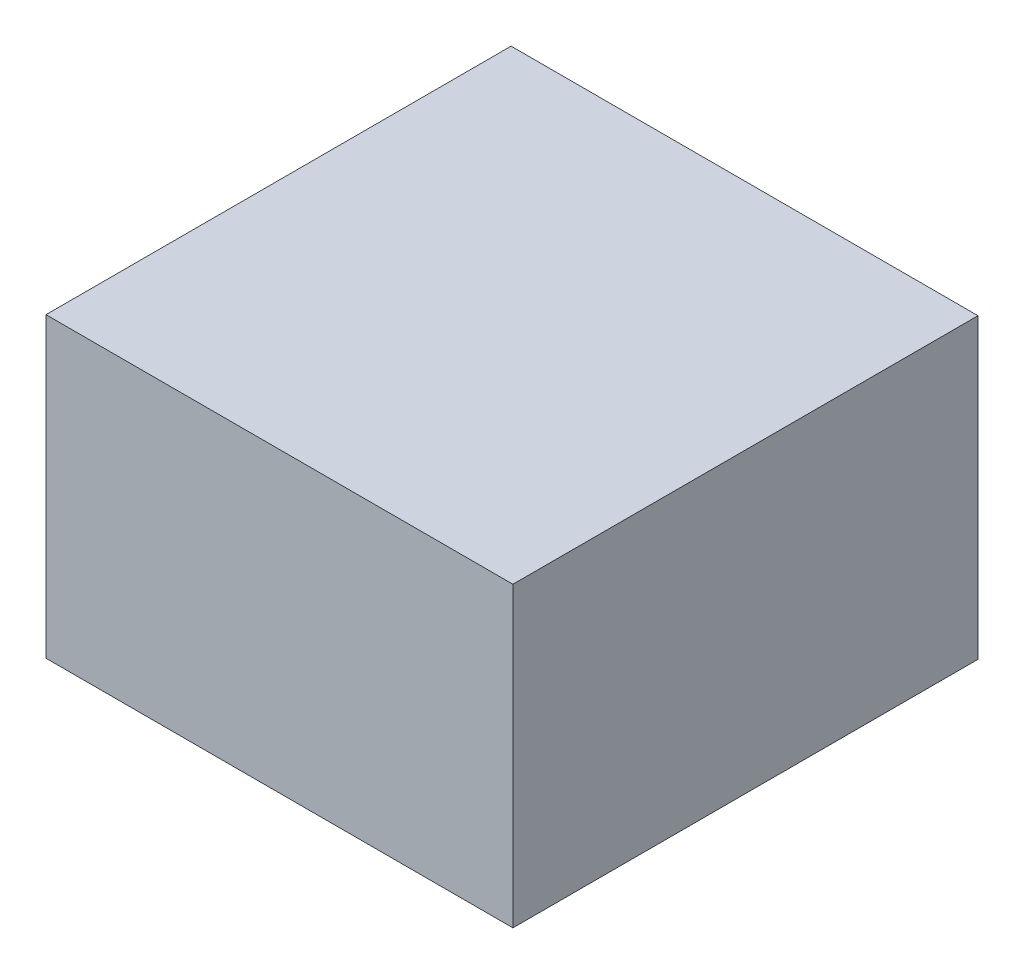
from build123d import *

# Parameters (mm, degrees)
SKETCH1_W           = 1285
SKETCH1_H           = 1280
BOSS_EXTRUDE1_DEPTH = 819


with BuildPart() as part:
    # Sketch1 → Boss-Extrude1 (new body)
    with BuildSketch(Plane(origin=(0, 0, 0), x_dir=(1, 0, 0), z_dir=(0, 1, 0))):
        Rectangle(SKETCH1_W, SKETCH1_H)
    extrude(amount=BOSS_EXTRUDE1_DEPTH)


solid = part.part
